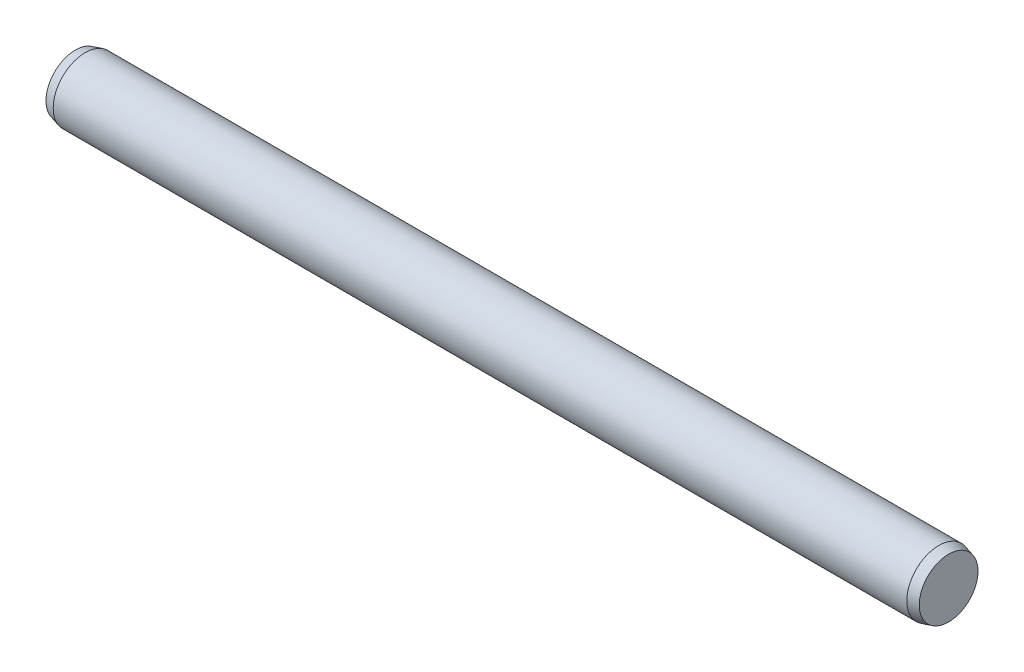
from build123d import *

# Parameters (mm, degrees)
SKETCH2_R           = 0.75
EXTRUDE1_DEPTH      = 10
EXTRUDE1_DEPTH_BACK = 10
SKETCH3_R           = 0.75
EXTRUDE2_DEPTH      = 0.23
EXTRUDE2_TAPER      = 15
SKETCH4_R           = 0.75
EXTRUDE3_DEPTH      = 0.23
EXTRUDE3_TAPER      = 15


with BuildPart() as part:
    # Sketch2 → Extrude1 (new body, two sides)
    with BuildSketch(Plane(origin=(0, 0, 0), x_dir=(0, 0, -1), z_dir=(1, 0, 0))) as extrude1_sk:
        Circle(SKETCH2_R)
    extrude(amount=EXTRUDE1_DEPTH)
    extrude(extrude1_sk.sketch, amount=-EXTRUDE1_DEPTH_BACK)

    # Sketch3 → Extrude2 (add)
    with BuildSketch(Plane(origin=(10, 0, 0), x_dir=(0, 0, -1), z_dir=(1, 0, 0))):
        Circle(SKETCH3_R)
    extrude(amount=EXTRUDE2_DEPTH, taper=EXTRUDE2_TAPER)

    # Sketch4 → Extrude3 (add)
    with BuildSketch(Plane.ZY.offset(10)):
        Circle(SKETCH4_R)
    extrude(amount=EXTRUDE3_DEPTH, taper=EXTRUDE3_TAPER)


solid = part.part
